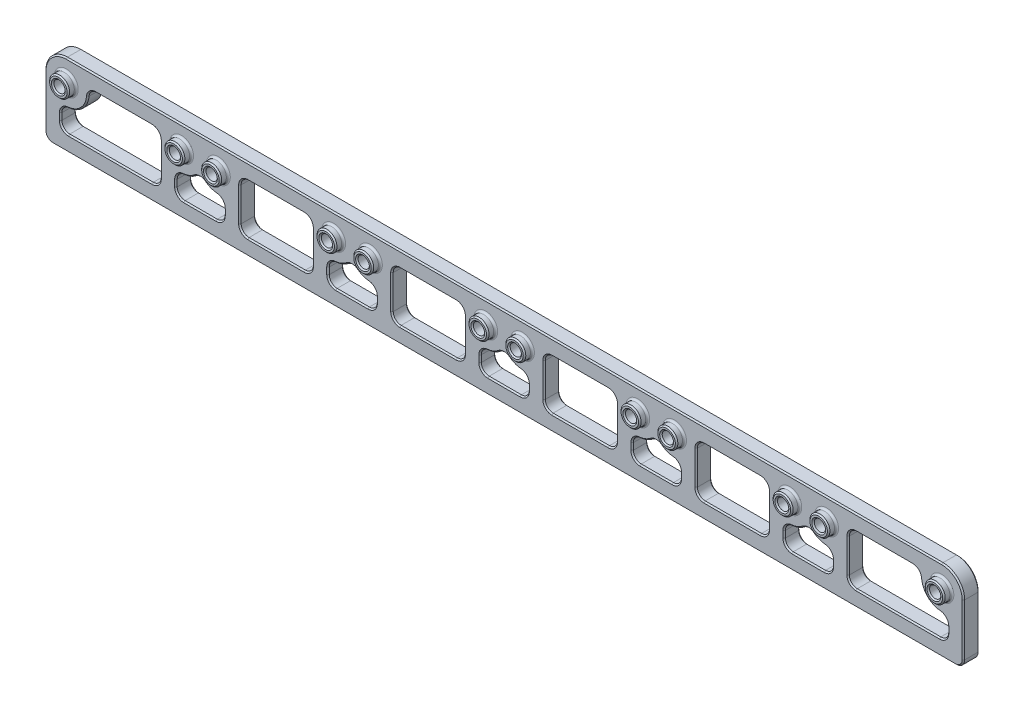
from build123d import *

# Parameters (mm, degrees)
SKETCH1_W               = 184.15
SKETCH1_H               = 16.3195
BOSS_EXTRUDE1_DEPTH     = 1.5875
SKETCH2_R               = 2.00025
BOSS_EXTRUDE2_DEPTH     = 1.5875
F_4_40_TAPPED_HOLE1_D   = 2.2606
CUT_EXTRUDE1_DEPTH      = 2.5875
CUT_EXTRUDE1_DEPTH_BACK = 4.175
FILLET1_R               = 0.396875
FILLET2_R               = 1.5875
CHAMFER2_SIZE           = 0.254


with BuildPart() as part:
    # Sketch1 → Boss-Extrude1 (new body, symmetric)
    with BuildSketch(Plane.XY):
        with Locations((0, -3.83921)):
            Rectangle(SKETCH1_W, SKETCH1_H)
    extrude(amount=BOSS_EXTRUDE1_DEPTH, both=True)

    # Sketch2 → Boss-Extrude2 (add)
    with BuildSketch(Plane.XY.offset(1.5875)):
        with Locations((-87.754460008, 0)):
            Circle(SKETCH2_R)
        with Locations((-64.645540008, 0)):
            Circle(SKETCH2_R)
        with Locations((-57.274460008, 0)):
            Circle(SKETCH2_R)
        with Locations((-34.16554, 0)):
            Circle(SKETCH2_R)
        with Locations((-26.79446, 0)):
            Circle(SKETCH2_R)
        with Locations((-3.68554, 0)):
            Circle(SKETCH2_R)
        with Locations((3.68554, 0)):
            Circle(SKETCH2_R)
        with Locations((26.79446, 0)):
            Circle(SKETCH2_R)
        with Locations((34.16554, 0)):
            Circle(SKETCH2_R)
        with Locations((57.27446, 0)):
            Circle(SKETCH2_R)
        with Locations((64.64554, 0)):
            Circle(SKETCH2_R)
        with Locations((87.75446, 0)):
            Circle(SKETCH2_R)
    extrude(amount=BOSS_EXTRUDE2_DEPTH)

    # #4-40 Tapped Hole1 (through all)
    with Locations(Plane.XY.offset(3.175)):
        with Locations((-87.754460008, 0), (-64.645540008, 0), (-57.274460008, 0), (-34.16554, 0), (-26.79446, 0), (-3.68554, 0), (3.68554, 0), (26.79446, 0), (34.16554, 0), (57.27446, 0), (64.64554, 0), (87.75446, 0)):
            Hole(F_4_40_TAPPED_HOLE1_D / 2)

    # Sketch5 → Cut-Extrude1 (cut, two sides)
    with BuildSketch(Plane.XY.offset(1.5875)) as cut_extrude1_sk:
        with BuildLine():
            Line((-83.584389529, 1.1303), (-68.815610487, 1.1303))
            ThreePointArc((-68.815610487, 1.1303), (-68.928297426, 0.570135766), (-68.966080008, 0))
            Line((-68.966080008, 0), (-68.966080008, -8.80872))
            Line((-68.966080008, -8.80872), (-88.88476, -8.80872))
            Line((-88.88476, -8.80872), (-88.88476, -4.170070481))
            ThreePointArc((-88.88476, -4.170070481), (-84.699376873, -3.055083129), (-83.584389529, 1.1303))
        make_face()
        with BuildLine():
            Line((-53.104389529, 1.1303), (-38.335610479, 1.1303))
            ThreePointArc((-38.335610479, 1.1303), (-38.448297418, 0.570135766), (-38.48608, 0))
            Line((-38.48608, 0), (-38.48608, -8.80872))
            Line((-38.48608, -8.80872), (-52.953920008, -8.80872))
            Line((-52.953920008, -8.80872), (-52.953920008, 0))
            ThreePointArc((-52.953920008, 0), (-52.99170259, 0.570135766), (-53.104389529, 1.1303))
        make_face()
        with BuildLine():
            Line((-22.624389521, 1.1303), (-7.855610479, 1.1303))
            ThreePointArc((-7.855610479, 1.1303), (-7.968297418, 0.570135766), (-8.00608, 0))
            Line((-8.00608, 0), (-8.00608, -8.80872))
            Line((-8.00608, -8.80872), (-22.47392, -8.80872))
            Line((-22.47392, -8.80872), (-22.47392, 0))
            ThreePointArc((-22.47392, 0), (-22.511702582, 0.570135766), (-22.624389521, 1.1303))
        make_face()
        with BuildLine():
            Line((7.855610479, 1.1303), (22.624389521, 1.1303))
            ThreePointArc((22.624389521, 1.1303), (22.511702582, 0.570135766), (22.47392, 0))
            Line((22.47392, 0), (22.47392, -8.80872))
            Line((22.47392, -8.80872), (8.00608, -8.80872))
            Line((8.00608, -8.80872), (8.00608, 0))
            ThreePointArc((8.00608, 0), (7.968297418, 0.570135766), (7.855610479, 1.1303))
        make_face()
        with BuildLine():
            Line((38.335610479, 1.1303), (53.104389521, 1.1303))
            ThreePointArc((53.104389521, 1.1303), (52.991702582, 0.570135766), (52.95392, 0))
            Line((52.95392, 0), (52.95392, -8.80872))
            Line((52.95392, -8.80872), (38.48608, -8.80872))
            Line((38.48608, -8.80872), (38.48608, 0))
            ThreePointArc((38.48608, 0), (38.448297418, 0.570135766), (38.335610479, 1.1303))
        make_face()
        with BuildLine():
            Line((68.815610479, 1.1303), (83.584389521, 1.1303))
            ThreePointArc((83.584389521, 1.1303), (84.699376868, -3.055083132), (88.88476, -4.170070479))
            Line((88.88476, -4.170070479), (88.88476, -8.80872))
            Line((88.88476, -8.80872), (68.96608, -8.80872))
            Line((68.96608, -8.80872), (68.96608, 0))
            ThreePointArc((68.96608, 0), (68.928297418, 0.570135766), (68.815610479, 1.1303))
        make_face()
        with BuildLine():
            Line((-65.775840008, -4.170070479), (-65.775840008, -8.80872))
            Line((-65.775840008, -8.80872), (-56.144160008, -8.80872))
            Line((-56.144160008, -8.80872), (-56.144160008, -4.170070479))
            ThreePointArc((-56.144160008, -4.170070479), (-58.871154658, -4.014677084), (-60.960000008, -2.254741848))
            ThreePointArc((-60.960000008, -2.254741848), (-63.048845358, -4.014677084), (-65.775840008, -4.170070479))
        make_face()
        with BuildLine():
            Line((-35.29584, -4.170070479), (-35.29584, -8.80872))
            Line((-35.29584, -8.80872), (-25.66416, -8.80872))
            Line((-25.66416, -8.80872), (-25.66416, -4.170070479))
            ThreePointArc((-25.66416, -4.170070479), (-28.39115465, -4.014677084), (-30.48, -2.254741848))
            ThreePointArc((-30.48, -2.254741848), (-32.56884535, -4.014677084), (-35.29584, -4.170070479))
        make_face()
        with BuildLine():
            Line((-4.81584, -4.170070479), (-4.81584, -8.80872))
            Line((-4.81584, -8.80872), (4.81584, -8.80872))
            Line((4.81584, -8.80872), (4.81584, -4.170070479))
            ThreePointArc((4.81584, -4.170070479), (2.08884535, -4.014677084), (0, -2.254741848))
            ThreePointArc((0, -2.254741848), (-2.08884535, -4.014677084), (-4.81584, -4.170070479))
        make_face()
        with BuildLine():
            Line((25.66416, -4.170070479), (25.66416, -8.80872))
            Line((25.66416, -8.80872), (35.29584, -8.80872))
            Line((35.29584, -8.80872), (35.29584, -4.170070479))
            ThreePointArc((35.29584, -4.170070479), (32.56884535, -4.014677084), (30.48, -2.254741848))
            ThreePointArc((30.48, -2.254741848), (28.39115465, -4.014677084), (25.66416, -4.170070479))
        make_face()
        with BuildLine():
            Line((56.14416, -4.170070479), (56.14416, -8.80872))
            Line((56.14416, -8.80872), (65.77584, -8.80872))
            Line((65.77584, -8.80872), (65.77584, -4.170070479))
            ThreePointArc((65.77584, -4.170070479), (63.04884535, -4.014677084), (60.96, -2.254741848))
            ThreePointArc((60.96, -2.254741848), (58.87115465, -4.014677084), (56.14416, -4.170070479))
        make_face()
        with BuildLine():
            Line((-92.075, 0), (-92.075, 4.32054))
            Line((-92.075, 4.32054), (-87.754460008, 4.32054))
            ThreePointArc((-87.754460008, 4.32054), (-90.80954314, 3.055083132), (-92.075, 0))
        make_face()
        with BuildLine():
            Line((87.75446, 4.32054), (92.075, 4.32054))
            Line((92.075, 4.32054), (92.075, 0))
            ThreePointArc((92.075, 0), (90.809543132, 3.055083132), (87.75446, 4.32054))
        make_face()
    extrude(amount=CUT_EXTRUDE1_DEPTH, mode=Mode.SUBTRACT)
    extrude(cut_extrude1_sk.sketch, amount=-CUT_EXTRUDE1_DEPTH_BACK, mode=Mode.SUBTRACT)

    # Fillet1
    fillet1_edges = [part.edges().sort_by_distance(p)[0] for p in [
        (-89.754710008, 0, 1.5875),
        (-66.645790008, 0, 1.5875),
        (-59.274710008, 0, 1.5875),
        (-36.16579, 0, 1.5875),
        (-28.79471, 0, 1.5875),
        (-5.68579, 0, 1.5875),
        (1.68529, 0, 1.5875),
        (24.79421, 0, 1.5875),
        (32.16529, 0, 1.5875),
        (55.27421, 0, 1.5875),
        (62.64529, 0, 1.5875),
        (85.75421, 0, 1.5875),
    ]]
    fillet(fillet1_edges, radius=FILLET1_R)

    # Fillet2
    fillet2_edges = [part.edges().sort_by_distance(p)[0] for p in [
        (-92.075, -11.99896, 0),
        (92.075, -11.99896, 0),
        (83.584389521, 1.1303, 0),
        (88.88476, -4.170070479, 0),
        (88.88476, -8.80872, 0),
        (68.96608, -8.80872, 0),
        (68.815610479, 1.1303, 0),
        (65.77584, -4.170070479, 0),
        (65.77584, -8.80872, 0),
        (56.14416, -8.80872, 0),
        (56.14416, -4.170070479, 0),
        (60.96, -2.254741848, 0),
        (53.104389521, 1.1303, 0),
        (52.95392, -8.80872, 0),
        (38.48608, -8.80872, 0),
        (38.335610479, 1.1303, 0),
        (25.66416, -4.170070479, 0),
        (30.48, -2.254741848, 0),
        (35.29584, -4.170070479, 0),
        (35.29584, -8.80872, 0),
        (25.66416, -8.80872, 0),
        (8.00608, -8.80872, 0),
        (22.47392, -8.80872, 0),
        (22.624389521, 1.1303, 0),
        (7.855610479, 1.1303, 0),
        (-4.81584, -4.170070479, 0),
        (4.81584, -4.170070479, 0),
        (0, -2.254741848, 0),
        (-4.81584, -8.80872, 0),
        (4.81584, -8.80872, 0),
        (-8.00608, -8.80872, 0),
        (-7.855610479, 1.1303, 0),
        (-22.624389521, 1.1303, 0),
        (-22.47392, -8.80872, 0),
        (-25.66416, -8.80872, 0),
        (-25.66416, -4.170070479, 0),
        (-30.48, -2.254741848, 0),
        (-35.29584, -4.170070479, 0),
        (-35.29584, -8.80872, 0),
        (-38.48608, -8.80872, 0),
        (-38.335610479, 1.1303, 0),
        (-53.104389529, 1.1303, 0),
        (-52.953920008, -8.80872, 0),
        (-56.144160008, -8.80872, 0),
        (-65.775840008, -8.80872, 0),
        (-65.775840008, -4.170070479, 0),
        (-56.144160008, -4.170070479, 0),
        (-88.88476, -4.170070481, 0),
        (-88.88476, -8.80872, 0),
        (-68.966080008, -8.80872, 0),
        (-68.815610487, 1.1303, 0),
        (-83.584389529, 1.1303, 0),
        (-60.960000008, -2.254741848, 0),
    ]]
    fillet(fillet2_edges, radius=FILLET2_R)

    # Chamfer2
    chamfer2_edges = [part.edges().sort_by_distance(p)[0] for p in [
        (-25.66416, 0, 3.175),
        (-25.66416, 0, -1.5875),
        (-33.03524, 0, 3.175),
        (-33.03524, 0, -1.5875),
        (-56.144160008, 0, 3.175),
        (-56.144160008, 0, -1.5875),
        (-63.515240008, 0, 3.175),
        (-63.515240008, 0, -1.5875),
        (-86.624160008, 0, 3.175),
        (-86.624160008, 0, -1.5875),
        (-4e-09, 4.32054, 1.5875),
        (-92.075, -5.20573, 1.5875),
        (-90.809543139, 3.055083134, 1.5875),
        (-89.754710008, 0, 3.175),
        (90.809543132, 3.055083132, 1.5875),
        (-92.075, -5.20573, -1.5875),
        (-4e-09, 4.32054, -1.5875),
        (-66.645790008, 0, 3.175),
        (-59.274710008, 0, 3.175),
        (90.809543132, 3.055083132, -1.5875),
        (-36.16579, 0, 3.175),
        (-28.79471, 0, 3.175),
        (-5.68579, 0, 3.175),
        (-90.809543139, 3.055083134, -1.5875),
        (1.68529, 0, 3.175),
        (24.79421, 0, 3.175),
        (32.16529, 0, 3.175),
        (55.27421, 0, 3.175),
        (0, -11.99896, -1.5875),
        (0, -11.99896, 1.5875),
        (-52.953920008, -3.83921, -1.5875),
        (-45.720000004, -8.80872, -1.5875),
        (-38.48608, -3.83921, -1.5875),
        (-45.720000004, 1.1303, -1.5875),
        (-84.699376873, -3.05508313, -1.5875),
        (-88.88476, -6.555771489, -1.5875),
        (-78.925420004, -8.80872, -1.5875),
        (-68.966080008, -3.83921, -1.5875),
        (-76.208858518, 1.1303, -1.5875),
        (92.075, -5.20573, -1.5875),
        (58.859128712, -4.019439136, -1.5875),
        (56.14416, -6.55577149, -1.5875),
        (60.96, -8.80872, -1.5875),
        (65.77584, -6.55577149, -1.5875),
        (63.060871288, -4.019439136, -1.5875),
        (28.379128712, -4.019439136, -1.5875),
        (25.66416, -6.55577149, -1.5875),
        (30.48, -8.80872, -1.5875),
        (35.29584, -6.55577149, -1.5875),
        (62.64529, 0, 3.175),
        (32.580871288, -4.019439136, -1.5875),
        (-2.100871288, -4.019439136, -1.5875),
        (-4.81584, -6.55577149, -1.5875),
        (0, -8.80872, -1.5875),
        (4.81584, -6.55577149, -1.5875),
        (2.100871288, -4.019439136, -1.5875),
        (-32.580871288, -4.019439136, -1.5875),
        (-35.29584, -6.55577149, -1.5875),
        (-30.48, -8.80872, -1.5875),
        (-25.66416, -6.55577149, -1.5875),
        (-28.379128712, -4.019439136, -1.5875),
        (-63.060871296, -4.019439136, -1.5875),
        (-65.775840008, -6.55577149, -1.5875),
        (-60.960000008, -8.80872, -1.5875),
        (-56.144160008, -6.55577149, -1.5875),
        (-58.85912872, -4.019439136, -1.5875),
        (-22.47392, -3.83921, -1.5875),
        (-15.24, -8.80872, -1.5875),
        (-8.00608, -3.83921, -1.5875),
        (-15.24, 1.1303, -1.5875),
        (8.00608, -3.83921, -1.5875),
        (15.24, -8.80872, -1.5875),
        (22.47392, -3.83921, -1.5875),
        (15.24, 1.1303, -1.5875),
        (38.48608, -3.83921, -1.5875),
        (45.72, -8.80872, -1.5875),
        (52.95392, -3.83921, -1.5875),
        (45.72, 1.1303, -1.5875),
        (68.96608, -3.83921, -1.5875),
        (78.92542, -8.80872, -1.5875),
        (88.88476, -6.55577149, -1.5875),
        (84.699376868, -3.055083132, -1.5875),
        (76.20885851, 1.1303, -1.5875),
        (91.610032015, -11.533992015, -1.5875),
        (-91.610032015, -11.533992015, -1.5875),
        (-52.953920008, -3.83921, 1.5875),
        (-45.720000004, 1.1303, 1.5875),
        (-38.48608, -3.83921, 1.5875),
        (-45.720000004, -8.80872, 1.5875),
        (-88.88476, -6.555771489, 1.5875),
        (-84.699376873, -3.05508313, 1.5875),
        (-76.208858518, 1.1303, 1.5875),
        (-68.966080008, -3.83921, 1.5875),
        (-78.925420004, -8.80872, 1.5875),
        (56.14416, -6.55577149, 1.5875),
        (58.859128712, -4.019439136, 1.5875),
        (63.060871288, -4.019439136, 1.5875),
        (65.77584, -6.55577149, 1.5875),
        (60.96, -8.80872, 1.5875),
        (25.66416, -6.55577149, 1.5875),
        (28.379128712, -4.019439136, 1.5875),
        (32.580871288, -4.019439136, 1.5875),
        (35.29584, -6.55577149, 1.5875),
        (30.48, -8.80872, 1.5875),
        (85.75421, 0, 3.175),
        (-4.81584, -6.55577149, 1.5875),
        (-2.100871288, -4.019439136, 1.5875),
        (2.100871288, -4.019439136, 1.5875),
        (4.81584, -6.55577149, 1.5875),
        (0, -8.80872, 1.5875),
        (-35.29584, -6.55577149, 1.5875),
        (-32.580871288, -4.019439136, 1.5875),
        (-28.379128712, -4.019439136, 1.5875),
        (-25.66416, -6.55577149, 1.5875),
        (-30.48, -8.80872, 1.5875),
        (-65.775840008, -6.55577149, 1.5875),
        (-63.060871296, -4.019439136, 1.5875),
        (-58.85912872, -4.019439136, 1.5875),
        (-56.144160008, -6.55577149, 1.5875),
        (-60.960000008, -8.80872, 1.5875),
        (-22.47392, -3.83921, 1.5875),
        (-15.24, 1.1303, 1.5875),
        (-8.00608, -3.83921, 1.5875),
        (-15.24, -8.80872, 1.5875),
        (8.00608, -3.83921, 1.5875),
        (15.24, 1.1303, 1.5875),
        (22.47392, -3.83921, 1.5875),
        (15.24, -8.80872, 1.5875),
        (38.48608, -3.83921, 1.5875),
        (45.72, 1.1303, 1.5875),
        (52.95392, -3.83921, 1.5875),
        (45.72, -8.80872, 1.5875),
        (68.96608, -3.83921, 1.5875),
        (76.20885851, 1.1303, 1.5875),
        (84.699376868, -3.055083132, 1.5875),
        (88.88476, -6.55577149, 1.5875),
        (78.92542, -8.80872, 1.5875),
        (92.075, -5.20573, 1.5875),
        (91.610032015, -11.533992015, 1.5875),
        (-91.610032015, -11.533992015, 1.5875),
        (82.942360388, 0.707956908, 1.5875),
        (82.942360388, 0.707956908, -1.5875),
        (88.462416908, -4.812099612, 1.5875),
        (88.462416908, -4.812099612, -1.5875),
        (88.419792015, -8.343752015, 1.5875),
        (88.419792015, -8.343752015, -1.5875),
        (69.431047985, -8.343752015, 1.5875),
        (69.431047985, -8.343752015, -1.5875),
        (69.431047985, 0.665332015, 1.5875),
        (69.431047985, 0.665332015, -1.5875),
        (65.353496908, -4.812099612, 1.5875),
        (65.353496908, -4.812099612, -1.5875),
        (65.310872015, -8.343752015, 1.5875),
        (65.310872015, -8.343752015, -1.5875),
        (56.609127985, -8.343752015, 1.5875),
        (56.609127985, -8.343752015, -1.5875),
        (56.566503092, -4.812099612, 1.5875),
        (56.566503092, -4.812099612, -1.5875),
        (60.96, -3.030046053, 1.5875),
        (60.96, -3.030046053, -1.5875),
        (52.488952015, 0.665332015, 1.5875),
        (52.488952015, 0.665332015, -1.5875),
        (52.488952015, -8.343752015, 1.5875),
        (52.488952015, -8.343752015, -1.5875),
        (38.951047985, -8.343752015, 1.5875),
        (38.951047985, -8.343752015, -1.5875),
        (38.951047985, 0.665332015, 1.5875),
        (38.951047985, 0.665332015, -1.5875),
        (26.086503092, -4.812099612, 1.5875),
        (26.086503092, -4.812099612, -1.5875),
        (30.48, -3.030046053, 1.5875),
        (30.48, -3.030046053, -1.5875),
        (34.873496908, -4.812099612, 1.5875),
        (34.873496908, -4.812099612, -1.5875),
        (34.830872015, -8.343752015, 1.5875),
        (34.830872015, -8.343752015, -1.5875),
        (26.129127985, -8.343752015, 1.5875),
        (26.129127985, -8.343752015, -1.5875),
        (8.471047985, -8.343752015, 1.5875),
        (8.471047985, -8.343752015, -1.5875),
        (22.008952015, -8.343752015, 1.5875),
        (22.008952015, -8.343752015, -1.5875),
        (22.008952015, 0.665332015, 1.5875),
        (22.008952015, 0.665332015, -1.5875),
        (8.471047985, 0.665332015, 1.5875),
        (8.471047985, 0.665332015, -1.5875),
        (-4.393496908, -4.812099612, 1.5875),
        (-4.393496908, -4.812099612, -1.5875),
        (4.393496908, -4.812099612, 1.5875),
        (4.393496908, -4.812099612, -1.5875),
        (0, -3.030046053, 1.5875),
        (0, -3.030046053, -1.5875),
        (-4.350872015, -8.343752015, 1.5875),
        (-4.350872015, -8.343752015, -1.5875),
        (4.350872015, -8.343752015, 1.5875),
        (4.350872015, -8.343752015, -1.5875),
        (-8.471047985, -8.343752015, 1.5875),
        (-8.471047985, -8.343752015, -1.5875),
        (-8.471047985, 0.665332015, 1.5875),
        (-8.471047985, 0.665332015, -1.5875),
        (-22.008952015, 0.665332015, 1.5875),
        (-22.008952015, 0.665332015, -1.5875),
        (-22.008952015, -8.343752015, 1.5875),
        (-22.008952015, -8.343752015, -1.5875),
        (-26.129127985, -8.343752015, 1.5875),
        (-26.129127985, -8.343752015, -1.5875),
        (-26.086503092, -4.812099612, 1.5875),
        (-26.086503092, -4.812099612, -1.5875),
        (-30.48, -3.030046053, 1.5875),
        (-30.48, -3.030046053, -1.5875),
        (-34.873496908, -4.812099612, 1.5875),
        (-34.873496908, -4.812099612, -1.5875),
        (-34.830872015, -8.343752015, 1.5875),
        (-34.830872015, -8.343752015, -1.5875),
        (-38.951047985, -8.343752015, 1.5875),
        (-38.951047985, -8.343752015, -1.5875),
        (-38.951047985, 0.665332015, 1.5875),
        (-38.951047985, 0.665332015, -1.5875),
        (-52.488952023, 0.665332015, 1.5875),
        (-52.488952023, 0.665332015, -1.5875),
        (-52.488952023, -8.343752015, 1.5875),
        (-52.488952023, -8.343752015, -1.5875),
        (-56.609127993, -8.343752015, 1.5875),
        (-56.609127993, -8.343752015, -1.5875),
        (-65.310872023, -8.343752015, 1.5875),
        (-65.310872023, -8.343752015, -1.5875),
        (-65.353496916, -4.812099612, 1.5875),
        (-65.353496916, -4.812099612, -1.5875),
        (-56.5665031, -4.812099612, 1.5875),
        (-56.5665031, -4.812099612, -1.5875),
        (-88.462416908, -4.812099612, 1.5875),
        (-88.462416908, -4.812099612, -1.5875),
        (-88.419792015, -8.343752015, 1.5875),
        (-88.419792015, -8.343752015, -1.5875),
        (-69.431047993, -8.343752015, 1.5875),
        (-69.431047993, -8.343752015, -1.5875),
        (-69.431047993, 0.665332015, 1.5875),
        (-69.431047993, 0.665332015, -1.5875),
        (-82.942360396, 0.707956908, 1.5875),
        (-82.942360396, 0.707956908, -1.5875),
        (-60.960000008, -3.030046053, 1.5875),
        (-60.960000008, -3.030046053, -1.5875),
        (88.88476, 0, 3.175),
        (88.88476, 0, -1.5875),
        (65.77584, 0, 3.175),
        (65.77584, 0, -1.5875),
        (58.40476, 0, 3.175),
        (58.40476, 0, -1.5875),
        (35.29584, 0, 3.175),
        (35.29584, 0, -1.5875),
        (27.92476, 0, 3.175),
        (27.92476, 0, -1.5875),
        (4.81584, 0, 3.175),
        (4.81584, 0, -1.5875),
        (-2.55524, 0, 3.175),
        (-2.55524, 0, -1.5875),
    ]]
    chamfer(chamfer2_edges, length=CHAMFER2_SIZE)


solid = part.part
